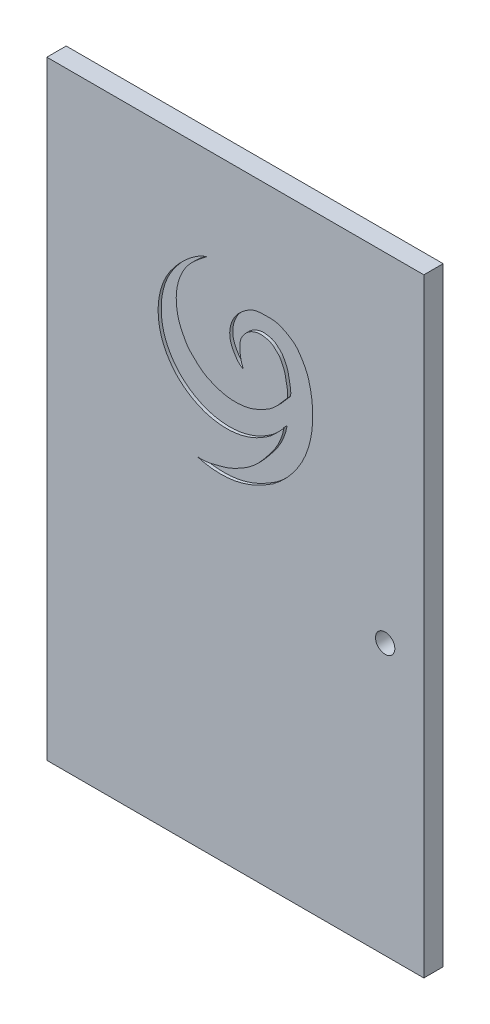
from build123d import *

# Parameters (mm, degrees)
SKETCH1_W           = 123.825
SKETCH1_H           = 200.025
BOSS_EXTRUDE1_DEPTH = 6.35
CUT_EXTRUDE1_DEPTH  = 1
SKETCH3_R           = 3.175
CUT_EXTRUDE5_DEPTH  = 6.35


with BuildPart() as part:
    # Sketch1 → Boss-Extrude1 (new body)
    with BuildSketch(Plane.XY):
        with Locations((0, 100.0125)):
            Rectangle(SKETCH1_W, SKETCH1_H)
    extrude(amount=BOSS_EXTRUDE1_DEPTH)

    # Sketch2 → Cut-Extrude1 (cut)
    with BuildSketch(Plane.XY.offset(6.35)):
        with BuildLine():
            add(Edge.make_bspline(
                [(-9.3315137, 169.569243245), (-11.197682458, 168.0976913), (-14.473708818, 165.721233019), (-17.3515287, 161.55448265), (-18.744772102, 157.97825035), (-19.57008031, 154.001795446), (-19.358235831, 149.934925708), (-18.469822241, 146.12187465), (-17.124182712, 143.444668775), (-15.644034584, 140.599586864), (-13.588642306, 138.679050764), (-11.836257338, 136.982177805), (-10.077256706, 135.678856281), (-7.853613512, 134.599615465), (-5.185304822, 133.61558172), (-2.047786445, 132.897639564), (1.519421734, 132.841261276), (5.39237554, 133.515486042), (8.762284385, 135.063456784), (13.159045788, 137.534995882), (15.41933096, 140.673664776), (17.148115982, 142.599332984)],
                knots=[0, 0, 0, 0, 0.099961909, 0.167105029, 0.208449478, 0.26000516, 0.335840189, 0.376754282, 0.422870274, 0.460837159, 0.509980806, 0.539098001, 0.563057055, 0.601178667, 0.642018306, 0.681938728, 0.735202325, 0.790245849, 0.844804461, 0.889640513, 1, 1, 1, 1], degree=3))
            add(Edge.make_bspline(
                [(17.148115982, 142.599332984), (17.367564898, 144.13870869), (16.733511702, 146.581109303), (16.27851799, 149.765590012), (15.257046991, 151.728449354), (14.513019179, 153.196973861), (13.240823028, 154.375565069), (11.745568369, 155.781281157), (9.683821258, 156.19357481), (7.817396792, 156.396871018), (6.203806641, 155.97816213), (4.652965895, 155.265249531), (3.330558451, 154.147368605), (2.264943334, 152.806256443), (1.516548282, 151.083064738), (1.371346174, 147.894578102), (1.84694368, 145.341424214), (2.595738039, 143.569491513)],
                knots=[0, 0, 0, 0, 0.129227486, 0.217526215, 0.272879708, 0.318699717, 0.357375737, 0.421225341, 0.491051763, 0.532380112, 0.58197413, 0.631697637, 0.678188113, 0.729298629, 0.777918757, 0.836782647, 1, 1, 1, 1], degree=3))
            add(Edge.make_bspline(
                [(2.595738039, 143.569491513), (1.091260425, 144.310158379), (-0.219261636, 146.215388888), (-1.583212927, 149.064413701), (-2.047008332, 151.87724563), (-1.347571294, 155.191523623), (0.573453598, 158.349369243), (2.984260186, 160.391278639), (6.053225923, 162.32432944), (9.778943871, 162.556297831), (14.026176553, 162.441587138), (17.093369221, 160.81063786), (19.954602244, 158.976975505), (21.782777067, 156.302763768), (23.650890625, 153.012737551), (25.241855425, 147.240745591), (25.735418593, 140.388419647), (24.627732078, 133.63565983), (23.078571098, 129.062371922), (21.165081325, 125.256739903), (18.863141262, 122.066101255), (16.769401407, 119.576261489), (14.765247422, 117.697271946), (12.495470846, 115.768794509), (9.628425201, 114.075558071), (6.510664621, 112.417594108), (3.292717559, 111.195822905), (-0.597926715, 110.157178984), (-5.997823526, 109.821254189), (-10.108137267, 110.358818405), (-12.480099704, 111.116416453)],
                knots=[0, 0, 0, 0, 0.042580268, 0.060224686, 0.08386458, 0.116965183, 0.148096973, 0.180452989, 0.200374999, 0.24344269, 0.276533285, 0.312238472, 0.333844074, 0.366401949, 0.396661336, 0.434486559, 0.524427596, 0.57712071, 0.615572447, 0.652537223, 0.689999449, 0.720028669, 0.738935019, 0.763057377, 0.799114426, 0.827221945, 0.85696418, 0.890507339, 0.9340038, 1, 1, 1, 1], degree=3))
            add(Edge.make_bspline(
                [(-12.480099704, 111.116416453), (-10.129509341, 110.851795977), (-6.766504791, 111.676958112), (-1.98778411, 112.975517751), (2.16491123, 115.032216309), (6.576646899, 117.974608303), (9.964617235, 122.001460334), (13.774755311, 126.773576412), (15.547642905, 130.861311443), (16.02148027, 133.6801336)],
                knots=[0, 0, 0, 0, 0.176744277, 0.265013981, 0.379273682, 0.53095193, 0.667955404, 0.780622384, 1, 1, 1, 1], degree=3))
            add(Edge.make_bspline(
                [(16.02148027, 133.6801336), (15.284751167, 132.546381486), (13.729522727, 131.07018515), (11.664732098, 129.010614657), (9.597669158, 127.664469948), (7.112988668, 126.179760231), (3.800643978, 124.813352957), (0.241003836, 124.010205105), (-4.0915461, 123.798546407), (-9.411378564, 124.519214898), (-14.89887892, 127.064106493), (-19.214250688, 130.610000296), (-21.908165408, 134.091041706), (-25.432890172, 140.742158426), (-25.903440928, 149.142146476), (-23.050507432, 157.045363775), (-19.622590138, 162.033808821), (-15.135925354, 166.48695288), (-11.34416307, 168.928938218), (-9.3315137, 169.569243245)],
                knots=[0, 0, 0, 0, 0.046226378, 0.074002645, 0.100379959, 0.131070976, 0.173920494, 0.22349156, 0.256215817, 0.323367781, 0.406730252, 0.461306621, 0.514924876, 0.557488619, 0.720548112, 0.782951714, 0.845978771, 0.927692708, 1, 1, 1, 1], degree=3))
        make_face()
    extrude(amount=-CUT_EXTRUDE1_DEPTH, mode=Mode.SUBTRACT)

    # Sketch3 → Cut-Extrude5 (cut)
    with BuildSketch(Plane.XY):
        with Locations((49.2125, 88.9)):
            Circle(SKETCH3_R)
    extrude(amount=CUT_EXTRUDE5_DEPTH, mode=Mode.SUBTRACT)


solid = part.part
